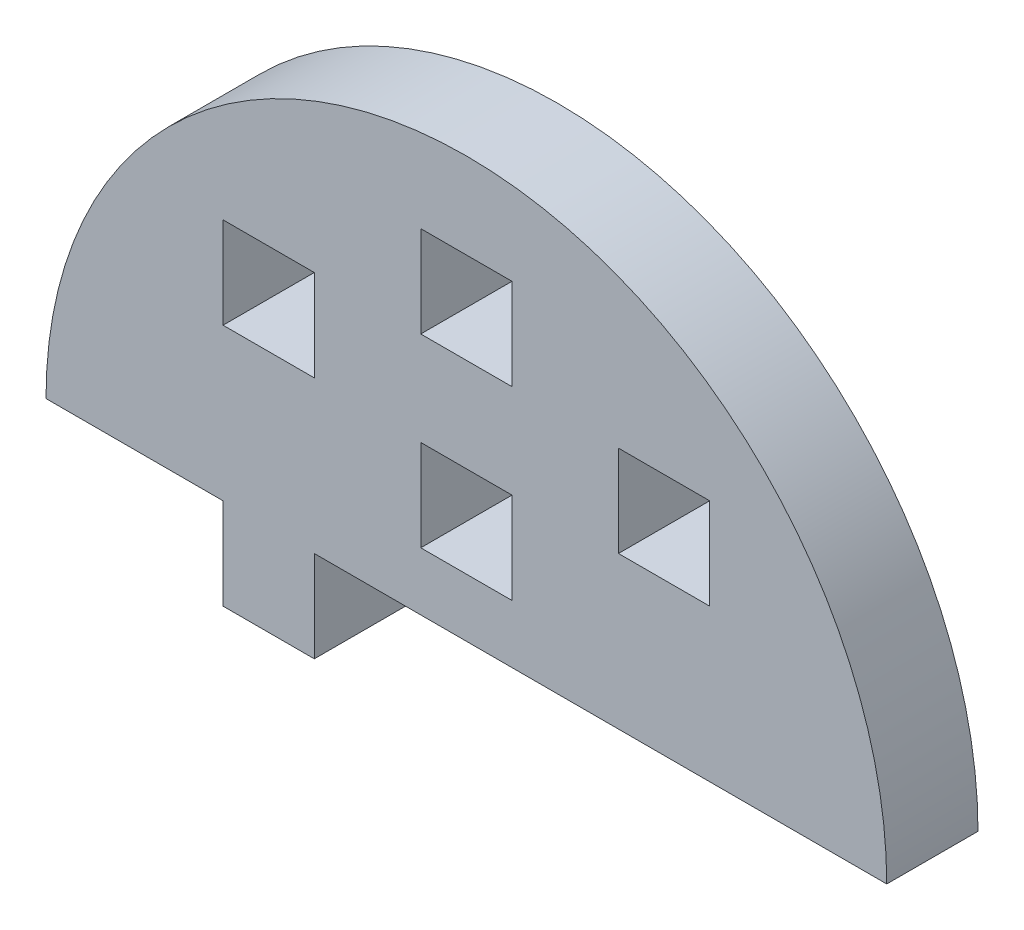
from build123d import *

# Parameters (mm, degrees)
MODEL_W             = 6
MODEL_H             = 6
BOSS_EXTRUDE1_DEPTH = 6


with BuildPart() as part:
    # Model → Boss-Extrude1 (new body)
    with BuildSketch(Plane.XY):
        with BuildLine():
            Line((3491.847275697, 1193.017146611), (3491.847275697, 1187.017146611))
            Line((3491.847275697, 1187.017146611), (3485.847275697, 1187.017146611))
            Line((3485.847275697, 1187.017146611), (3485.847275697, 1193.017146611))
            Line((3485.847275697, 1193.017146611), (3474.204418554, 1193.017146611))
            ThreePointArc((3474.204418554, 1193.017146611), (3501.847275697, 1220.660003754), (3529.49013284, 1193.017146611))
            Line((3529.49013284, 1193.017146611), (3491.847275697, 1193.017146611))
        make_face()
        with Locations((3514.847275697, 1206.017146611)):
            Rectangle(MODEL_W, MODEL_H, mode=Mode.SUBTRACT)
        with Locations((3488.847275697, 1206.017146611)):
            Rectangle(MODEL_W, MODEL_H, mode=Mode.SUBTRACT)
        with Locations((3501.847275697, 1212.017146611)):
            Rectangle(MODEL_W, MODEL_H, mode=Mode.SUBTRACT)
        with Locations((3501.847275697, 1199.841605445)):
            Rectangle(MODEL_W, MODEL_H, mode=Mode.SUBTRACT)
    extrude(amount=BOSS_EXTRUDE1_DEPTH)


solid = part.part
